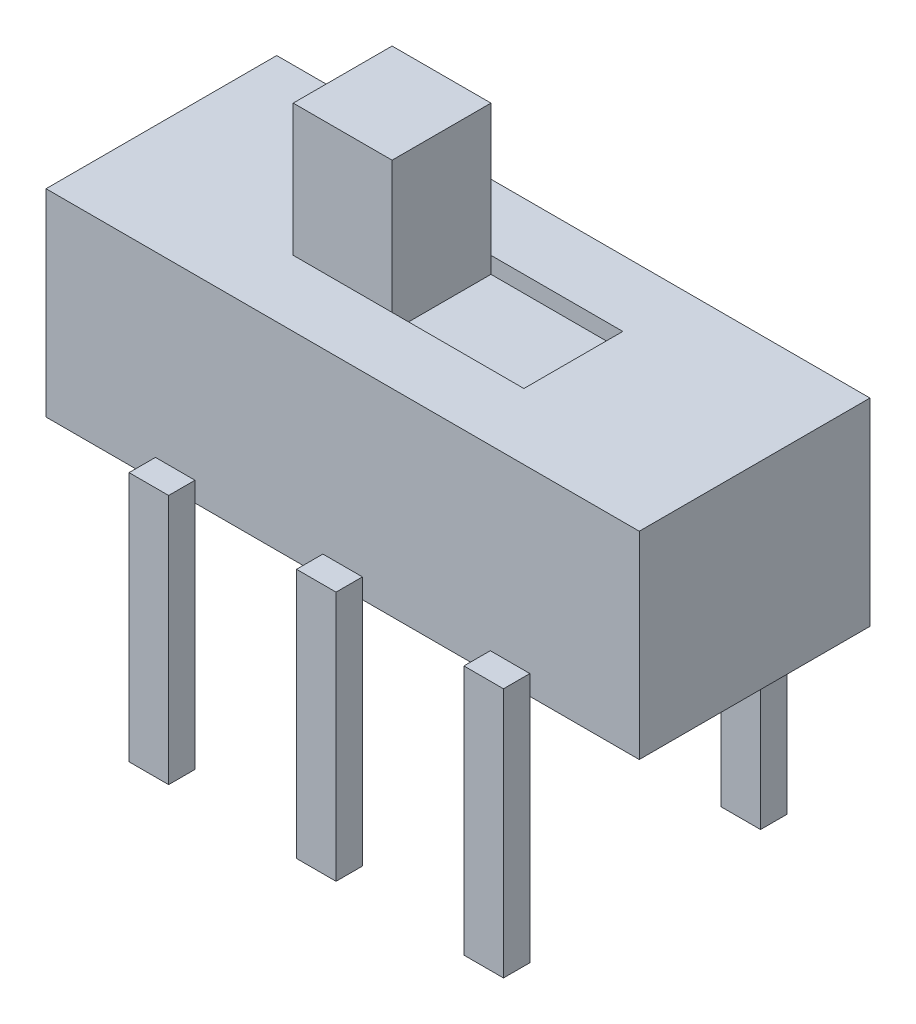
from build123d import *

# Parameters (mm, degrees)
ESQUISSE1_W                = 9
ESQUISSE1_H                = 3.5
BOSS_EXTRU_1_DEPTH         = 3
ESQUISSE2_W                = 1.5
ESQUISSE2_H                = 1.5
BOSS_EXTRU_2_DEPTH         = 2
ESQUISSE3_W                = 2
ESQUISSE3_H                = 1.5
ENL_V_MAT_EXTRU_1_DEPTH    = 0.25
ESQUISSE4_W                = 0.6
ESQUISSE4_H                = 3.8
BOSS_EXTRU_3_DEPTH         = 0.4
R_P_TITION_LIN_AIRE1_COUNT = 3
R_P_TITION_LIN_AIRE1_PITCH = 2.54


with BuildPart() as part:
    # Esquisse1 → Boss.-Extru.1 (new body)
    with BuildSketch(Plane(origin=(0, 0, 0), x_dir=(1, 0, 0), z_dir=(0, 1, 0))):
        Rectangle(ESQUISSE1_W, ESQUISSE1_H)
    extrude(amount=BOSS_EXTRU_1_DEPTH)

    # Esquisse2 → Boss.-Extru.2 (add)
    with BuildSketch(Plane(origin=(0, 3, 0), x_dir=(1, 0, 0), z_dir=(0, 1, 0))):
        with Locations((-1, 0)):
            Rectangle(ESQUISSE2_W, ESQUISSE2_H)
    extrude(amount=BOSS_EXTRU_2_DEPTH)

    # Esquisse3 → Enlèv. mat.-Extru.1 (cut)
    with BuildSketch(Plane(origin=(0, 3, 0), x_dir=(1, 0, 0), z_dir=(0, 1, 0))):
        with Locations((0.75, 0)):
            Rectangle(ESQUISSE3_W, ESQUISSE3_H)
    extrude(amount=-ENL_V_MAT_EXTRU_1_DEPTH, mode=Mode.SUBTRACT)


with BuildPart() as body_2:
    # Esquisse4 → Boss.-Extru.3 (new body)
    with BuildSketch(Plane.XY.offset(1.75)):
        with Locations((-2.54, -1.6)):
            Rectangle(ESQUISSE4_W, ESQUISSE4_H)
    extrude(amount=BOSS_EXTRU_3_DEPTH)


with BuildPart() as r_p_tition_lin_aire1_1:
    # Répétition linéaire1: pattern copy
    add(body_2.part.moved(Location(Vector(1, 0, 0) * (1 * R_P_TITION_LIN_AIRE1_PITCH))))


with BuildPart() as r_p_tition_lin_aire1_2:
    # Répétition linéaire1: pattern copy
    add(body_2.part.moved(Location(Vector(1, 0, 0) * (2 * R_P_TITION_LIN_AIRE1_PITCH))))


with BuildPart() as body_5:
    # Symétrie1: mirrored copy
    add(body_2.part.mirror(Plane.XY))


with BuildPart() as body_6:
    # Sym_trie1 2: mirrored copy
    add(r_p_tition_lin_aire1_1.part.mirror(Plane.XY))


with BuildPart() as body_7:
    # Sym_trie1 3: mirrored copy
    add(r_p_tition_lin_aire1_2.part.mirror(Plane.XY))


solid = Compound([part.part, body_2.part, r_p_tition_lin_aire1_1.part, r_p_tition_lin_aire1_2.part, body_5.part, body_6.part, body_7.part])
